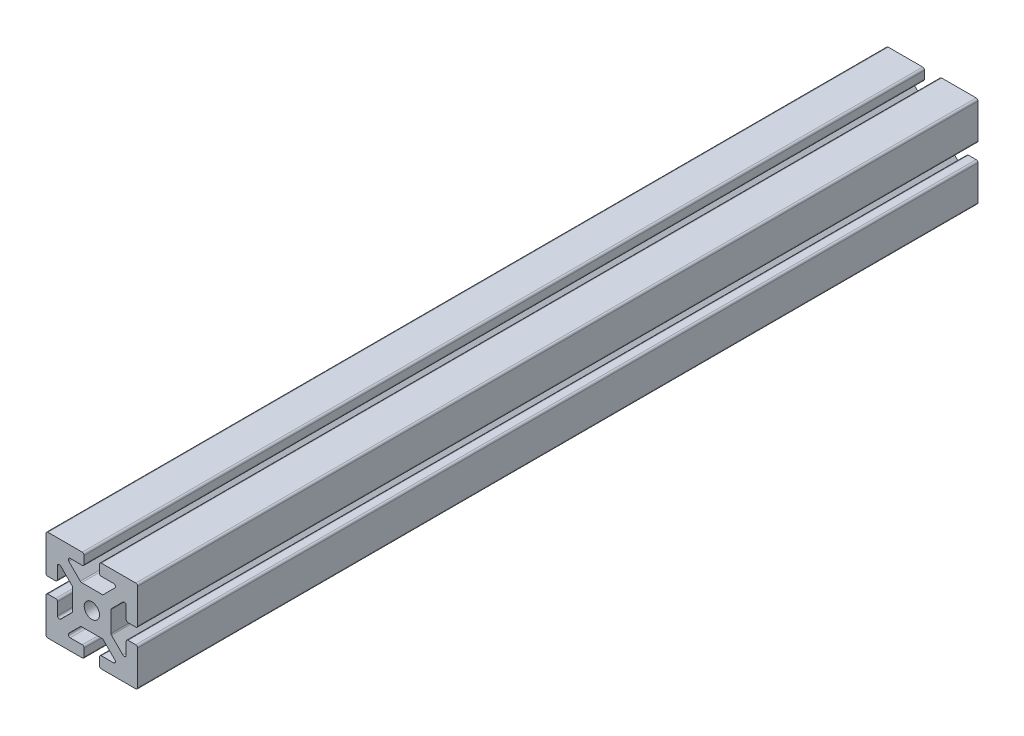
from build123d import *

# Parameters (mm, degrees)
SKETCH1_R           = 1
BOSS_EXTRUDE1_DEPTH = 55


with BuildPart() as part:
    # Sketch1 → Boss-Extrude1 (new body, symmetric)
    with BuildSketch(Plane.XY):
        with BuildLine():
            ThreePointArc((-6, 1.25), (-5.926776695, 1.073223305), (-5.75, 1))
            Line((-5.75, 1), (-4.75, 1))
            ThreePointArc((-4.75, 1), (-4.573223305, 1.073223305), (-4.5, 1.25))
            Line((-4.5, 1.25), (-4.5, 2.835786438))
            ThreePointArc((-4.5, 2.835786438), (-4.345670858, 3.066756321), (-4.073223305, 3.012563133))
            Line((-4.073223305, 3.012563133), (-2.573223305, 1.512563133))
            ThreePointArc((-2.573223305, 1.512563133), (-2.519030117, 1.431457296), (-2.5, 1.335786438))
            Line((-2.5, 1.335786438), (-2.5, -1.335786438))
            ThreePointArc((-2.5, -1.335786438), (-2.519030117, -1.431457296), (-2.573223305, -1.512563133))
            Line((-2.573223305, -1.512563133), (-4.073223305, -3.012563133))
            ThreePointArc((-4.073223305, -3.012563133), (-4.345670858, -3.066756321), (-4.5, -2.835786438))
            Line((-4.5, -2.835786438), (-4.5, -1.25))
            ThreePointArc((-4.5, -1.25), (-4.573223305, -1.073223305), (-4.75, -1))
            Line((-4.75, -1), (-5.75, -1))
            ThreePointArc((-5.75, -1), (-5.926776695, -1.073223305), (-6, -1.25))
            Line((-6, -1.25), (-6, -5.75))
            ThreePointArc((-6, -5.75), (-5.926776695, -5.926776695), (-5.75, -6))
            Line((-5.75, -6), (-1.25, -6))
            ThreePointArc((-1.25, -6), (-1.073223305, -5.926776695), (-1, -5.75))
            Line((-1, -5.75), (-1, -4.75))
            ThreePointArc((-1, -4.75), (-1.073223305, -4.573223305), (-1.25, -4.5))
            Line((-1.25, -4.5), (-2.835786438, -4.5))
            ThreePointArc((-2.835786438, -4.5), (-3.066756321, -4.345670858), (-3.012563133, -4.073223305))
            Line((-3.012563133, -4.073223305), (-1.512563133, -2.573223305))
            ThreePointArc((-1.512563133, -2.573223305), (-1.431457296, -2.519030117), (-1.335786438, -2.5))
            Line((-1.335786438, -2.5), (1.335786438, -2.5))
            ThreePointArc((1.335786438, -2.5), (1.431457296, -2.519030117), (1.512563133, -2.573223305))
            Line((1.512563133, -2.573223305), (3.012563133, -4.073223305))
            ThreePointArc((3.012563133, -4.073223305), (3.066756321, -4.345670858), (2.835786438, -4.5))
            Line((2.835786438, -4.5), (1.25, -4.5))
            ThreePointArc((1.25, -4.5), (1.073223305, -4.573223305), (1, -4.75))
            Line((1, -4.75), (1, -5.75))
            ThreePointArc((1, -5.75), (1.073223305, -5.926776695), (1.25, -6))
            Line((1.25, -6), (5.75, -6))
            ThreePointArc((5.75, -6), (5.926776695, -5.926776695), (6, -5.75))
            Line((6, -5.75), (6, -1.25))
            ThreePointArc((6, -1.25), (5.926776695, -1.073223305), (5.75, -1))
            Line((5.75, -1), (4.75, -1))
            ThreePointArc((4.75, -1), (4.573223305, -1.073223305), (4.5, -1.25))
            Line((4.5, -1.25), (4.5, -2.835786438))
            ThreePointArc((4.5, -2.835786438), (4.345670858, -3.066756321), (4.073223305, -3.012563133))
            Line((4.073223305, -3.012563133), (2.573223305, -1.512563133))
            ThreePointArc((2.573223305, -1.512563133), (2.519030117, -1.431457296), (2.5, -1.335786438))
            Line((2.5, -1.335786438), (2.5, 1.335786438))
            ThreePointArc((2.5, 1.335786438), (2.519030117, 1.431457296), (2.573223305, 1.512563133))
            Line((2.573223305, 1.512563133), (4.073223305, 3.012563133))
            ThreePointArc((4.073223305, 3.012563133), (4.345670858, 3.066756321), (4.5, 2.835786438))
            Line((4.5, 2.835786438), (4.5, 1.25))
            ThreePointArc((4.5, 1.25), (4.573223305, 1.073223305), (4.75, 1))
            Line((4.75, 1), (5.75, 1))
            ThreePointArc((5.75, 1), (5.926776695, 1.073223305), (6, 1.25))
            Line((6, 1.25), (6, 5.75))
            ThreePointArc((6, 5.75), (5.926776695, 5.926776695), (5.75, 6))
            Line((5.75, 6), (1.25, 6))
            ThreePointArc((1.25, 6), (1.073223305, 5.926776695), (1, 5.75))
            Line((1, 5.75), (1, 4.75))
            ThreePointArc((1, 4.75), (1.073223305, 4.573223305), (1.25, 4.5))
            Line((1.25, 4.5), (2.835786438, 4.5))
            ThreePointArc((2.835786438, 4.5), (3.066756321, 4.345670858), (3.012563133, 4.073223305))
            Line((3.012563133, 4.073223305), (1.439339828, 2.5))
            Line((1.439339828, 2.5), (-1.335786438, 2.5))
            ThreePointArc((-1.335786438, 2.5), (-1.431457296, 2.519030117), (-1.512563133, 2.573223305))
            Line((-1.512563133, 2.573223305), (-3.012563133, 4.073223305))
            ThreePointArc((-3.012563133, 4.073223305), (-3.066756321, 4.345670858), (-2.835786438, 4.5))
            Line((-2.835786438, 4.5), (-1.25, 4.5))
            ThreePointArc((-1.25, 4.5), (-1.073223305, 4.573223305), (-1, 4.75))
            Line((-1, 4.75), (-1, 5.75))
            ThreePointArc((-1, 5.75), (-1.073223305, 5.926776695), (-1.25, 6))
            Line((-1.25, 6), (-5.75, 6))
            ThreePointArc((-5.75, 6), (-5.926776695, 5.926776695), (-6, 5.75))
            Line((-6, 5.75), (-6, 1.25))
        make_face()
        Circle(SKETCH1_R, mode=Mode.SUBTRACT)
    extrude(amount=BOSS_EXTRUDE1_DEPTH, both=True)


solid = part.part
